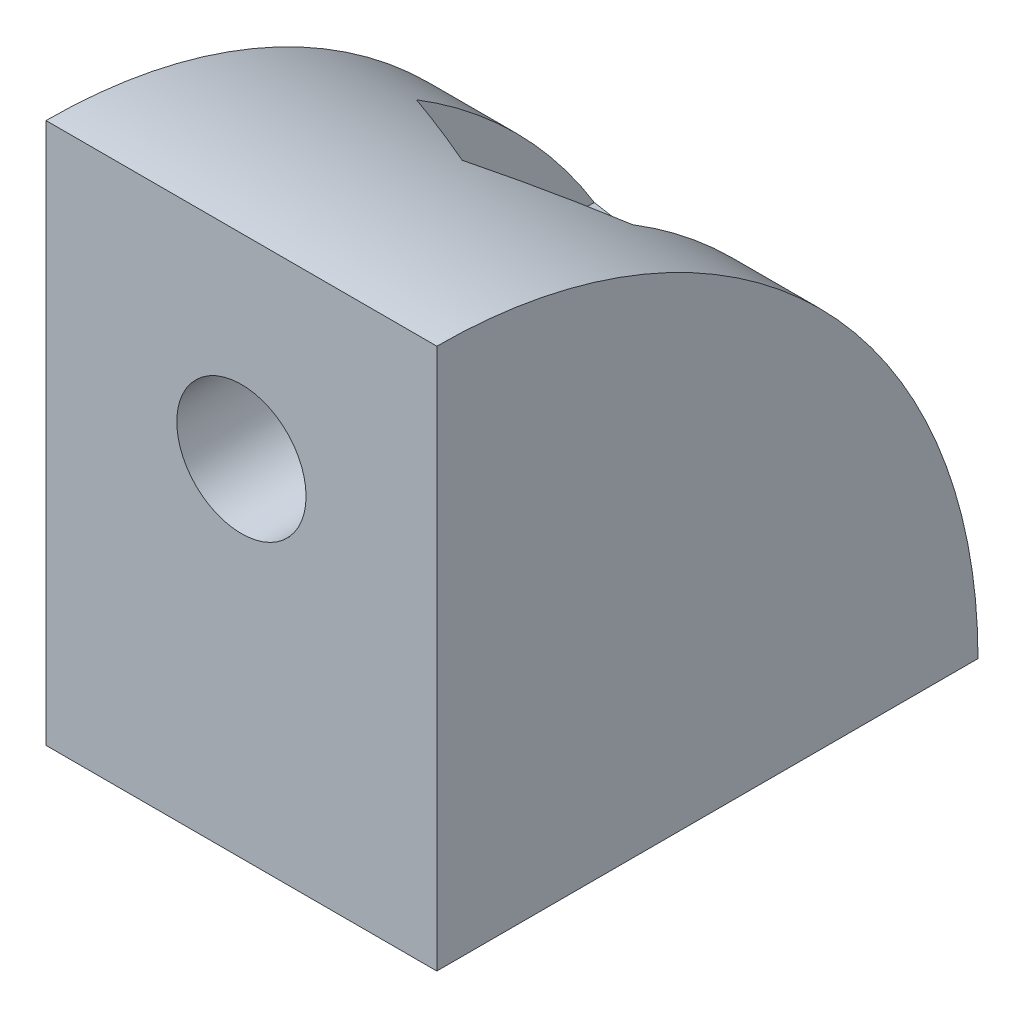
from build123d import *

# Parameters (mm, degrees)
EXTRUDE1_DEPTH = 13
SKETCH3_R      = 2.15
EXTRUDE2_DEPTH = 30
EXTRUDE3_START = -4
EXTRUDE3_DEPTH = 30


with BuildPart() as part:
    # Sketch2 → Extrude1 (new body)
    with BuildSketch(Plane(origin=(0, 0, 0), x_dir=(0, 0, -1), z_dir=(1, 0, 0))):
        with BuildLine():
            Line((0, 0), (18, 0))
            ThreePointArc((18, 0), (12.727922061, 12.727922061), (0, 18))
            Line((0, 18), (0, 0))
        make_face()
    extrude(amount=EXTRUDE1_DEPTH)

    # Sketch3 → Extrude2 (cut)
    with BuildSketch(Plane.XY):
        with Locations((6.5, 11.5)):
            Circle(SKETCH3_R)
    extrude2 = extrude(amount=-EXTRUDE2_DEPTH, mode=Mode.SUBTRACT)

    # Sketch5 → Extrude3 (cut)
    with BuildSketch(Plane.XY.offset(EXTRUDE3_START)):
        Polygon((6.5, 15.656921938), (2.9, 13.578460969), (2.9, 9.421539031), (6.5, 7.343078062), (10.1, 9.421539031), (10.1, 13.578460969), align=None)
    extrude3 = extrude(amount=-EXTRUDE3_DEPTH, mode=Mode.SUBTRACT)

    # Mirror1: Extrude2, Extrude3 across plane
    add(extrude2.mirror(Plane(origin=(0, 0, 0), x_dir=(0, -0.707106781, 0.707106781), z_dir=(0, 0.707106781, 0.707106781))), mode=Mode.SUBTRACT)
    add(extrude3.mirror(Plane(origin=(0, 0, 0), x_dir=(0, -0.707106781, 0.707106781), z_dir=(0, 0.707106781, 0.707106781))), mode=Mode.SUBTRACT)


solid = part.part
